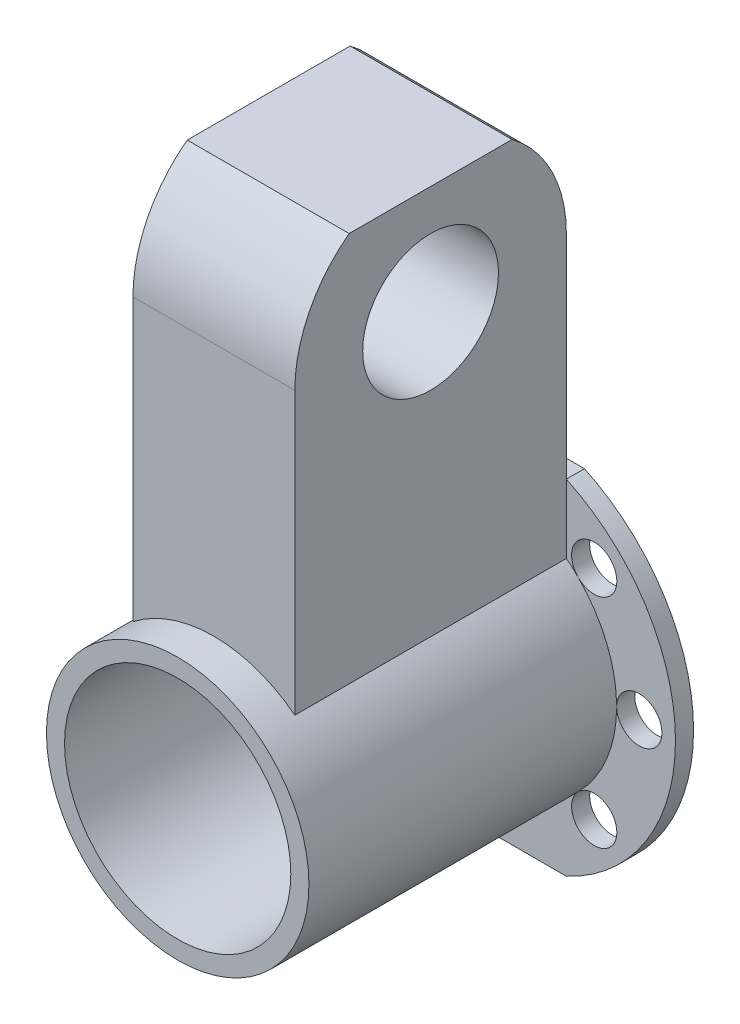
from build123d import *

# Parameters (mm, degrees)
IZIM1_R                          = 14.5
IZIM1_R_2                        = 12.5
Y_KSEKLIK_EKSTR_ZYON1_DEPTH      = 34
IZIM2_R                          = 21
IZIM2_R_2                        = 12.5
Y_KSEKLIK_EKSTR_ZYON2_DEPTH      = 2
IZIM3_R                          = 2.5
KES_EKSTR_ZYON1_DEPTH            = 78
KES_EKSTR_ZYON2_DEPTH            = 78
Y_KSEKLIK_EKSTR_ZYON5_REACH      = 54.146
Y_KSEKLIK_EKSTR_ZYON5_END_RADIUS = 14.5
IZIM6_W                          = 30
IZIM6_H                          = 17.88854382
Y_KSEKLIK_EKSTR_ZYON6_DEPTH      = 40
IZIM10_R                         = 7.5
KES_EKSTR_ZYON3_DEPTH            = 30
KES_EKSTR_ZYON4_DEPTH            = 93


with BuildPart() as part:
    # Çizim1 → Yükseklik-Ekstrüzyon1 (new body)
    with BuildSketch(Plane.XY):
        Circle(IZIM1_R)
        Circle(IZIM1_R_2, mode=Mode.SUBTRACT)
    extrude(amount=Y_KSEKLIK_EKSTR_ZYON1_DEPTH)



with BuildPart() as body_2:
    # Çizim2 → Yükseklik-Ekstrüzyon2 (new body)
    with BuildSketch(Plane(origin=(0, 0, 0), x_dir=(-1, 0, 0), z_dir=(0, 0, -1))):
        Circle(IZIM2_R)
        with Locations(Location((0, 0, 0), (0, 0, 180))):
            Circle(IZIM2_R_2, mode=Mode.SUBTRACT)
    extrude(amount=Y_KSEKLIK_EKSTR_ZYON2_DEPTH)

    # Çizim3 → Kes-Ekstrüzyon1 (cut)
    with BuildSketch(Plane(origin=(0, 0, -2), x_dir=(-1, 0, 0), z_dir=(0, 0, -1))):
        with Locations((-17, 0)):
            Circle(IZIM3_R)
        with Locations((-12.02081528, 12.02081528)):
            Circle(IZIM3_R)
        with Locations((12.02081528, 12.02081528)):
            Circle(IZIM3_R)
        with Locations((17, 0)):
            Circle(IZIM3_R)
        with Locations((12.02081528, -12.02081528)):
            Circle(IZIM3_R)
        with Locations((-12.02081528, -12.02081528)):
            Circle(IZIM3_R)
    extrude(amount=-KES_EKSTR_ZYON1_DEPTH, mode=Mode.SUBTRACT)

    # Çizim4 → Kes-Ekstrüzyon2 (cut)
    with BuildSketch(Plane(origin=(0, 0, -2), x_dir=(-1, 0, 0), z_dir=(0, 0, -1))):
        with BuildLine():
            Line((-8.94427191, 19), (8.94427191, 19))
            ThreePointArc((8.94427191, 19), (0, 21), (-8.94427191, 19))
        make_face()
        with BuildLine():
            Line((-8.94427191, -19), (8.94427191, -19))
            ThreePointArc((8.94427191, -19), (0, -21), (-8.94427191, -19))
        make_face()
    extrude(amount=-KES_EKSTR_ZYON2_DEPTH, mode=Mode.SUBTRACT)


with BuildPart() as part_1:
    add(part.part)

    add(body_2.part)  # Yükseklik-Ekstrüzyon5 merges body 2
    # Yükseklik-Ekstrüzyon5: up to this cylinder (the profile starts outside it)
    y_kseklik_ekstr_zyon5_end = Plane(origin=(0, 0, 15), z_dir=(0, 0, -1)) * Cylinder(Y_KSEKLIK_EKSTR_ZYON5_END_RADIUS, 138.292, mode=Mode.PRIVATE)
    # Çizim6 → Yükseklik-Ekstrüzyon5 (add, up to the surface)
    with BuildSketch(Plane(origin=(0, 14.5, 0), x_dir=(0, 0, -1), z_dir=(0, 1, 0)), mode=Mode.PRIVATE) as y_kseklik_ekstr_zyon5_sk1:
        with Locations((-15, 0)):
            Rectangle(IZIM6_W, IZIM6_H)
    y_kseklik_ekstr_zyon5_tool1 = extrude(y_kseklik_ekstr_zyon5_sk1.sketch, amount=-Y_KSEKLIK_EKSTR_ZYON5_REACH, mode=Mode.PRIVATE) - y_kseklik_ekstr_zyon5_end
    add(y_kseklik_ekstr_zyon5_tool1.solids().sort_by_distance((0, 14.5, 15))[0])
    add(y_kseklik_ekstr_zyon5_tool1.solids().sort_by_distance((0, 14.5, 15))[1])

    # Çizim9 → Yükseklik-Ekstrüzyon6 (add)
    with BuildSketch(Plane(origin=(0, 14.5, 0), x_dir=(1, 0, 0), z_dir=(0, 1, 0))):
        Polygon((-8.94427191, -30), (0, -30), (8.94427191, -30), (8.94427191, 0), (-8.94427191, 0), align=None)
    extrude(amount=Y_KSEKLIK_EKSTR_ZYON6_DEPTH)

    # Çizim10 → Kes-Ekstrüzyon3 (cut)
    with BuildSketch(Plane.ZY.offset(8.94427191)):
        with Locations(Location((15, 42.5, 0), (0, 0, 270))):
            Circle(IZIM10_R)
    extrude(amount=-KES_EKSTR_ZYON3_DEPTH, mode=Mode.SUBTRACT)

    # Çizim11 → Kes-Ekstrüzyon4 (cut)
    with BuildSketch(Plane.ZY.offset(8.94427191)):
        with BuildLine():
            Line((30, 42.5), (30, 54.5))
            Line((30, 54.5), (24, 54.5))
            ThreePointArc((24, 54.5), (28.416407865, 49.208203932), (30, 42.5))
        make_face()
        with BuildLine():
            Line((0, 54.5), (6, 54.5))
            ThreePointArc((6, 54.5), (1.583592135, 49.208203932), (0, 42.5))
            Line((0, 42.5), (0, 54.5))
        make_face()
    extrude(amount=-KES_EKSTR_ZYON4_DEPTH, mode=Mode.SUBTRACT)


solid = part_1.part
